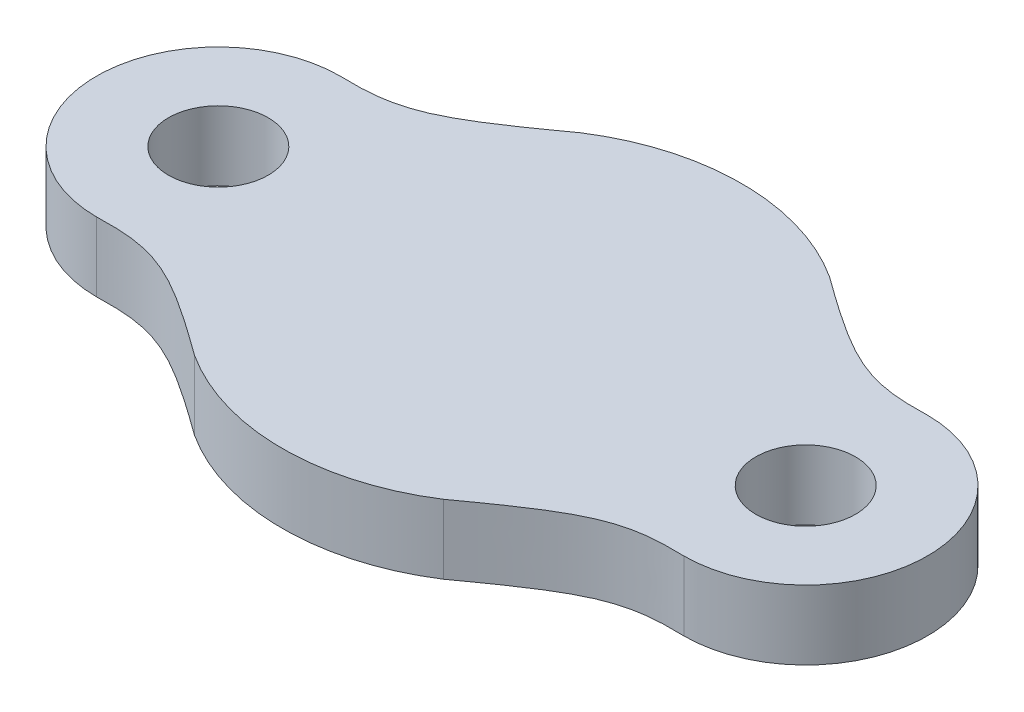
from build123d import *

# Parameters (mm, degrees)
CROQUIS1_R              = 1.143
SALIENTE_EXTRUIR6_DEPTH = 1.5875


with BuildPart() as part:
    # Croquis1 → Saliente-Extruir6 (new body)
    with BuildSketch(Plane(origin=(0, 0, 0), x_dir=(1, 0, 0), z_dir=(0, 1, 0))):
        with BuildLine():
            ThreePointArc((-13.782319099, 2.794), (-16.576319099, 0), (-13.782319099, -2.794))
            add(Edge.make_bspline(
                [(-13.782319099, -2.794), (-12.381959509, -2.745210856), (-11.808442523, -3.043224941), (-9.906232869, -4.4207888)],
                knots=[0, 0, 0, 0, 1, 1, 1, 1], degree=3))
            ThreePointArc((-9.906232869, -4.4207888), (-7.051319099, -5.2625), (-4.196405329, -4.4207888))
            add(Edge.make_bspline(
                [(-4.196405329, -4.4207888), (-2.294195675, -3.043224941), (-1.720678689, -2.745210856), (-0.320319099, -2.794)],
                knots=[0.921934519, 0.921934519, 0.921934519, 0.921934519, 1.921934519, 1.921934519, 1.921934519, 1.921934519], degree=3))
            ThreePointArc((-0.320319099, -2.794), (2.473680901, 0), (-0.320319099, 2.794))
            add(Edge.make_bspline(
                [(-0.320319099, 2.794), (-1.720678689, 2.745210856), (-2.294195675, 3.043224941), (-4.196405329, 4.4207888)],
                knots=[0, 0, 0, 0, 1, 1, 1, 1], degree=3))
            ThreePointArc((-4.196405329, 4.4207888), (-7.051319099, 5.2625), (-9.906232869, 4.4207888))
            add(Edge.make_bspline(
                [(-9.906232869, 4.4207888), (-11.808442523, 3.043224941), (-12.381959509, 2.745210856), (-13.782319099, 2.794)],
                knots=[0.921934519, 0.921934519, 0.921934519, 0.921934519, 1.921934519, 1.921934519, 1.921934519, 1.921934519], degree=3))
        make_face()
        with Locations((-13.782319099, 0)):
            Circle(CROQUIS1_R, mode=Mode.SUBTRACT)
        with Locations((-0.320319099, 0)):
            Circle(CROQUIS1_R, mode=Mode.SUBTRACT)
    extrude(amount=SALIENTE_EXTRUIR6_DEPTH)


solid = part.part
